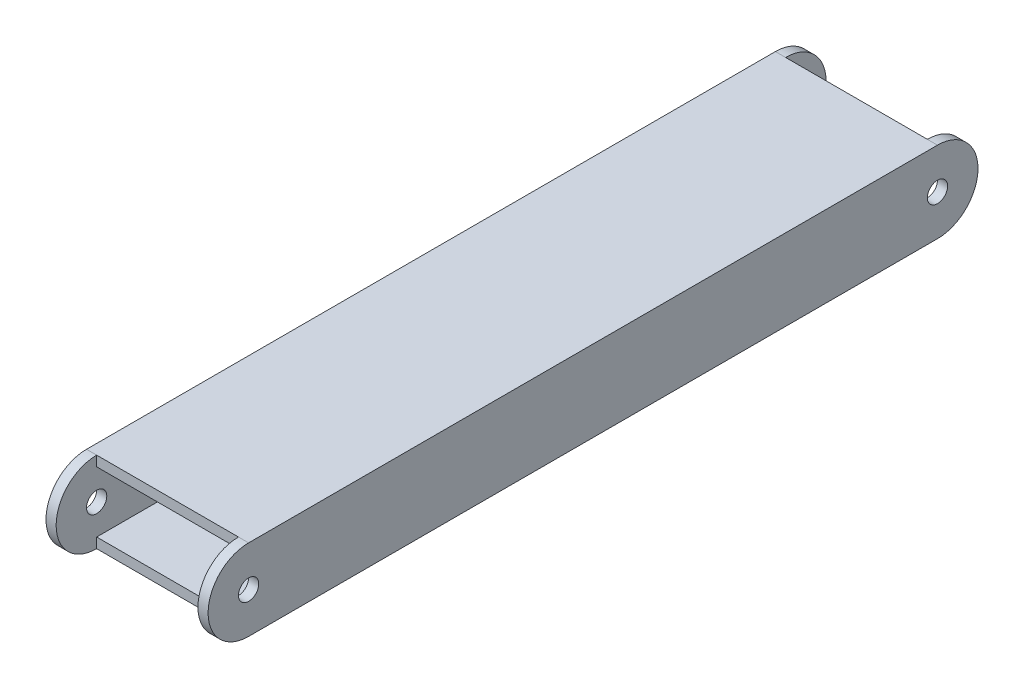
from build123d import *

# Parameters (mm, degrees)
LINK2OUTERLIP_W     = 50.8
LINK2OUTERLIP_H     = 25.4
LINK2OUTERLIP_W_2   = 44.45
LINK2OUTERLIP_H_2   = 19.05
EXTRUDE_THIN1_DEPTH = 215.9
BOSS_EXTRUDE1_DEPTH = 3.175
BOSS_EXTRUDE2_DEPTH = 3.175
SKETCH4_R           = 3.175
CUT_EXTRUDE1_DEPTH  = 50.8


with BuildPart() as part:
    # Link2OuterLip → Extrude-Thin1 (new body)
    with BuildSketch(Plane.XY):
        Rectangle(LINK2OUTERLIP_W, LINK2OUTERLIP_H)
        Rectangle(LINK2OUTERLIP_W_2, LINK2OUTERLIP_H_2, mode=Mode.SUBTRACT)
    extrude(amount=EXTRUDE_THIN1_DEPTH)

    # Sketch2 → Boss-Extrude1 (add)
    with BuildSketch(Plane.ZY.offset(25.4)):
        with BuildLine():
            Line((0, -12.7), (0, 12.7))
            ThreePointArc((0, 12.7), (-12.7, 0), (0, -12.7))
        make_face()
    boss_extrude1 = extrude(amount=-BOSS_EXTRUDE1_DEPTH)

    # Sketch3 → Boss-Extrude2 (add)
    with BuildSketch(Plane(origin=(25.4, 0, 0), x_dir=(0, 0, -1), z_dir=(1, 0, 0))):
        with BuildLine():
            Line((0, 12.7), (0, -12.7))
            ThreePointArc((0, -12.7), (12.7, 0), (0, 12.7))
        make_face()
    boss_extrude2 = extrude(amount=-BOSS_EXTRUDE2_DEPTH)

    # Sketch4 → Cut-Extrude1 (cut)
    with BuildSketch(Plane(origin=(25.4, 0, 0), x_dir=(0, 0, -1), z_dir=(1, 0, 0))):
        Circle(SKETCH4_R)
    cut_extrude1 = extrude(amount=-CUT_EXTRUDE1_DEPTH, mode=Mode.SUBTRACT)

    # Mirror1: Boss-Extrude1, Boss-Extrude2, Cut-Extrude1 across plane
    add(boss_extrude1.mirror(Plane.XY.offset(107.95)))
    add(boss_extrude2.mirror(Plane.XY.offset(107.95)))
    add(cut_extrude1.mirror(Plane.XY.offset(107.95)), mode=Mode.SUBTRACT)


solid = part.part
